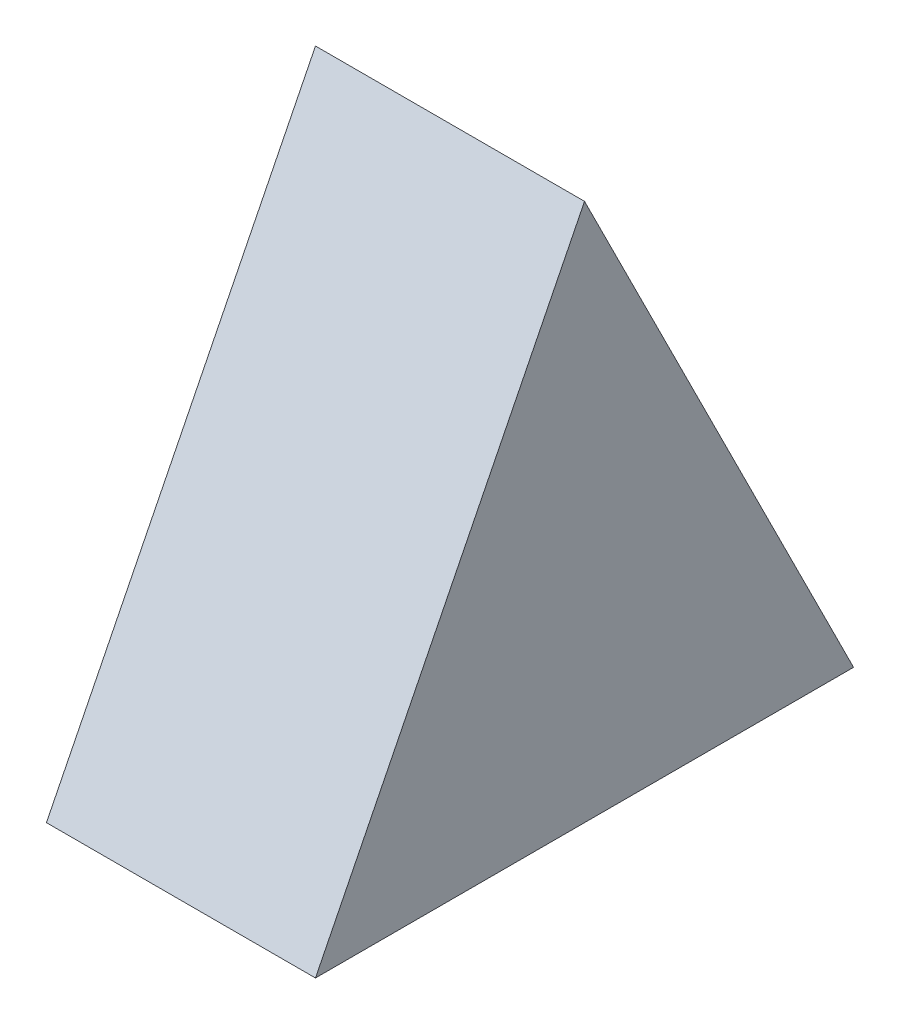
from build123d import *

# Parameters (mm, degrees)
SKETCH1_W           = 40
SKETCH1_H           = 40
BOSS_EXTRUDE1_DEPTH = 40
CUT_EXTRUDE1_DEPTH  = 40
CUT_EXTRUDE2_DEPTH  = 40
CUT_EXTRUDE3_DEPTH  = 40
CUT_EXTRUDE4_DEPTH  = 40


with BuildPart() as part:
    # Sketch1 → Boss-Extrude1 (new body)
    with BuildSketch(Plane.XY):
        with Locations((20, 20)):
            Rectangle(SKETCH1_W, SKETCH1_H)
    extrude(amount=BOSS_EXTRUDE1_DEPTH)

    # Sketch2 → Cut-Extrude1 (cut)
    with BuildSketch(Plane.XY.offset(40)):
        Polygon((0, 0), (20, 40), (0, 40), align=None)
    extrude(amount=-CUT_EXTRUDE1_DEPTH, mode=Mode.SUBTRACT)

    # Sketch3 → Cut-Extrude2 (cut)
    with BuildSketch(Plane.XZ):
        Polygon((0, 0), (20, 20), (20, 40), (0, 40), align=None)
    extrude(amount=-CUT_EXTRUDE2_DEPTH, mode=Mode.SUBTRACT)

    # Sketch4 → Cut-Extrude3 (cut)
    with BuildSketch(Plane.ZY.offset(-20)):
        Polygon((20, 40), (40, 0), (40, 40), align=None)
    extrude(amount=-CUT_EXTRUDE3_DEPTH, mode=Mode.SUBTRACT)

    # Sketch5 → Cut-Extrude4 (cut)
    with BuildSketch(Plane(origin=(0, 0, 0), x_dir=(1, 0, 0), z_dir=(0, -0.447213595, 0.894427191))):
        Polygon((0, 0), (40, 0), (40, 44.72135955), (20, 44.72135955), align=None)
    extrude(amount=-CUT_EXTRUDE4_DEPTH, mode=Mode.SUBTRACT)


solid = part.part
